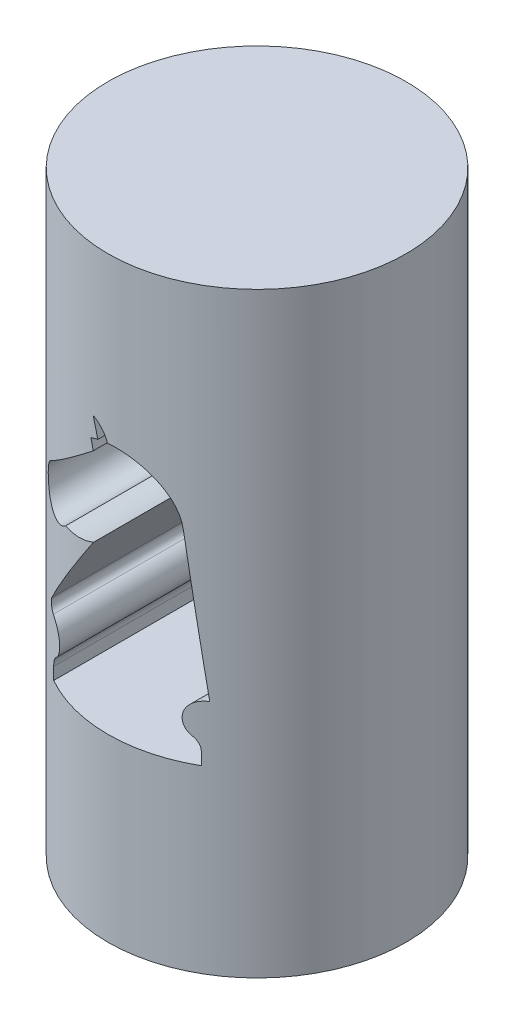
from build123d import *

# Parameters (mm, degrees)
SKETCH2_R               = 10
BOSS_EXTRUDE1_DEPTH     = 20
CUT_EXTRUDE1_DEPTH      = 11
CUT_EXTRUDE1_DEPTH_BACK = 11
SKETCH4_R               = 3
CUT_EXTRUDE2_DEPTH      = 3


with BuildPart() as part:
    # Sketch2 → Boss-Extrude1 (new body, symmetric)
    with BuildSketch(Plane(origin=(0, 0, 0), x_dir=(1, 0, 0), z_dir=(0, 1, 0))):
        Circle(SKETCH2_R)
    extrude(amount=BOSS_EXTRUDE1_DEPTH, both=True)

    # Sketch3 → Cut-Extrude1 (cut, two sides)
    with BuildSketch(Plane.XY) as cut_extrude1_sk:
        with BuildLine():
            Line((-4.95, -7.92), (4.95, -7.92))
            Line((4.95, -7.92), (4.95, -7.095))
            ThreePointArc((4.95, -7.095), (4.845529135, -6.638488486), (4.552912235, -6.272848946))
            ThreePointArc((4.552912235, -6.272848946), (4.163263898, -4.929032869), (5.303905651, -4.118721901))
            Line((5.303905651, -4.118721901), (4.152601488, 5.595942007))
            ThreePointArc((4.152601488, 5.595942007), (2.748128038, 8.13841183), (-0.032970708, 8.976378553))
            ThreePointArc((-0.032970708, 8.976378553), (-0.420174759, 9.631170394), (-1.043370943, 10.067410979))
            Line((-1.043370943, 10.067410979), (-0.704768531, 8.852119124))
            ThreePointArc((-0.704768531, 8.852119124), (-0.961731099, 8.770731362), (-1.212370482, 8.671566707))
            Line((-1.212370482, 8.671566707), (-1.043370943, 8.000640714))
            Line((-1.043370943, 8.000640714), (-5.45370194, 4.456357119))
            ThreePointArc((-5.45370194, 4.456357119), (-5.641905535, 2.260075199), (-3.43929894, 2.172902623))
            ThreePointArc((-3.43929894, 2.172902623), (-2.20642224, 2.304167352), (-1.029214799, 2.693266345))
            Line((-1.029214799, 2.693266345), (-5.262567741, -3.352870715))
            ThreePointArc((-5.262567741, -3.352870715), (-5.32769839, -3.799977219), (-5.007467138, -4.118721901))
            ThreePointArc((-5.007467138, -4.118721901), (-4.156142001, -5.081814751), (-4.58020402, -6.295270037))
            ThreePointArc((-4.58020402, -6.295270037), (-4.853076089, -6.654455711), (-4.95, -7.095))
            Line((-4.95, -7.095), (-4.95, -7.92))
        make_face()
    extrude(amount=CUT_EXTRUDE1_DEPTH, mode=Mode.SUBTRACT)
    extrude(cut_extrude1_sk.sketch, amount=-CUT_EXTRUDE1_DEPTH_BACK, mode=Mode.SUBTRACT)

    # Sketch4 → Cut-Extrude2 (cut)
    with BuildSketch(Plane(origin=(0, -20, 0), x_dir=(-1, 0, 0), z_dir=(0, -1, 0))):
        Circle(SKETCH4_R)
    extrude(amount=-CUT_EXTRUDE2_DEPTH, mode=Mode.SUBTRACT)


solid = part.part
